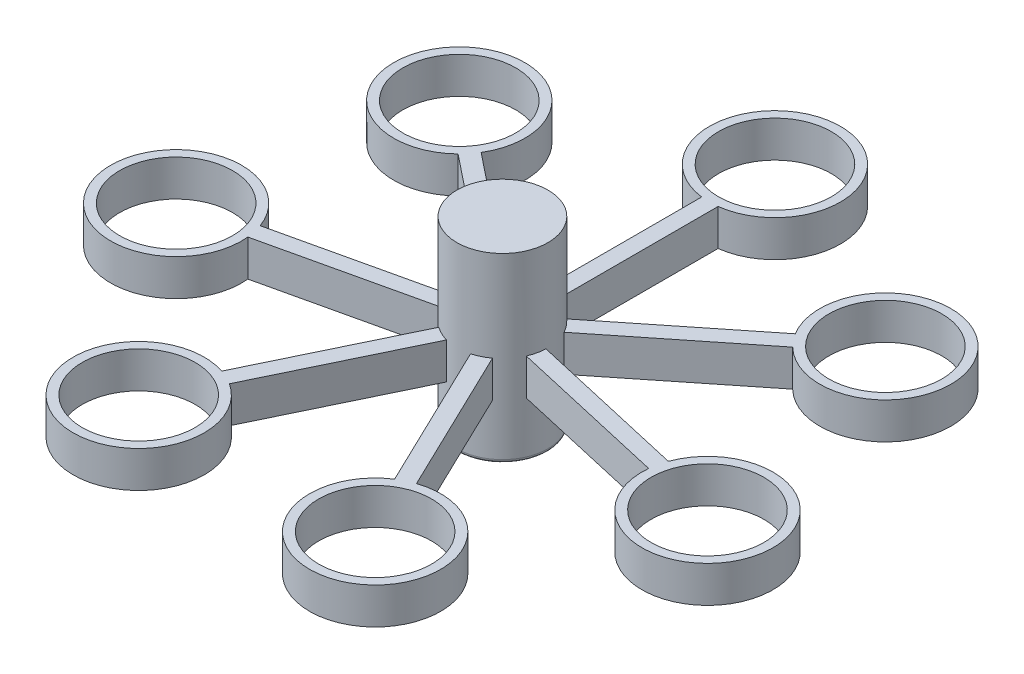
from build123d import *

# Parameters (mm, degrees)
SKETCH1_R           = 12.5
BOSS_EXTRUDE1_DEPTH = 50
BOSS_EXTRUDE2_START = 15
SKETCH3_R           = 15.5
BOSS_EXTRUDE2_DEPTH = 10
CIRPATTERN1_COUNT   = 7
FILLET1_R           = 1


with BuildPart() as part:
    # Sketch1 → Boss-Extrude1 (new body)
    with BuildSketch(Plane(origin=(0, 0, 0), x_dir=(1, 0, 0), z_dir=(0, 1, 0))):
        Circle(SKETCH1_R)
    extrude(amount=BOSS_EXTRUDE1_DEPTH)

    # Sketch3 → Boss-Extrude2 (add)
    with BuildSketch(Plane(origin=(0, 0, 0), x_dir=(1, 0, 0), z_dir=(0, 1, 0)).offset(BOSS_EXTRUDE2_START)):
        with BuildLine():
            Line((-2.253835774, 56.947383215), (-2.253835774, 12.295130105))
            Line((-2.253835774, 12.295130105), (2.253835774, 12.295130105))
            Line((2.253835774, 12.295130105), (2.253835774, 56.947383215))
            ThreePointArc((2.253835774, 56.947383215), (0, 92.805720885), (-2.253835774, 56.947383215))
        make_face()
        with Locations((0, 74.805720885)):
            Circle(SKETCH3_R, mode=Mode.SUBTRACT)
    boss_extrude2 = extrude(amount=BOSS_EXTRUDE2_DEPTH)

    # CirPattern1: Boss-Extrude2 ×7 about axis
    cirpattern1_axis = Axis((0, 0, 0), (0, 1, 0))
    for i in range(1, CIRPATTERN1_COUNT):
        add(boss_extrude2.rotate(cirpattern1_axis, i * 360 / CIRPATTERN1_COUNT))

    # Fillet1
    fillet1_edges = [part.edges().sort_by_distance(p)[0] for p in [
        (-12.5, 0, 0),
    ]]
    fillet(fillet1_edges, radius=FILLET1_R)


solid = part.part
